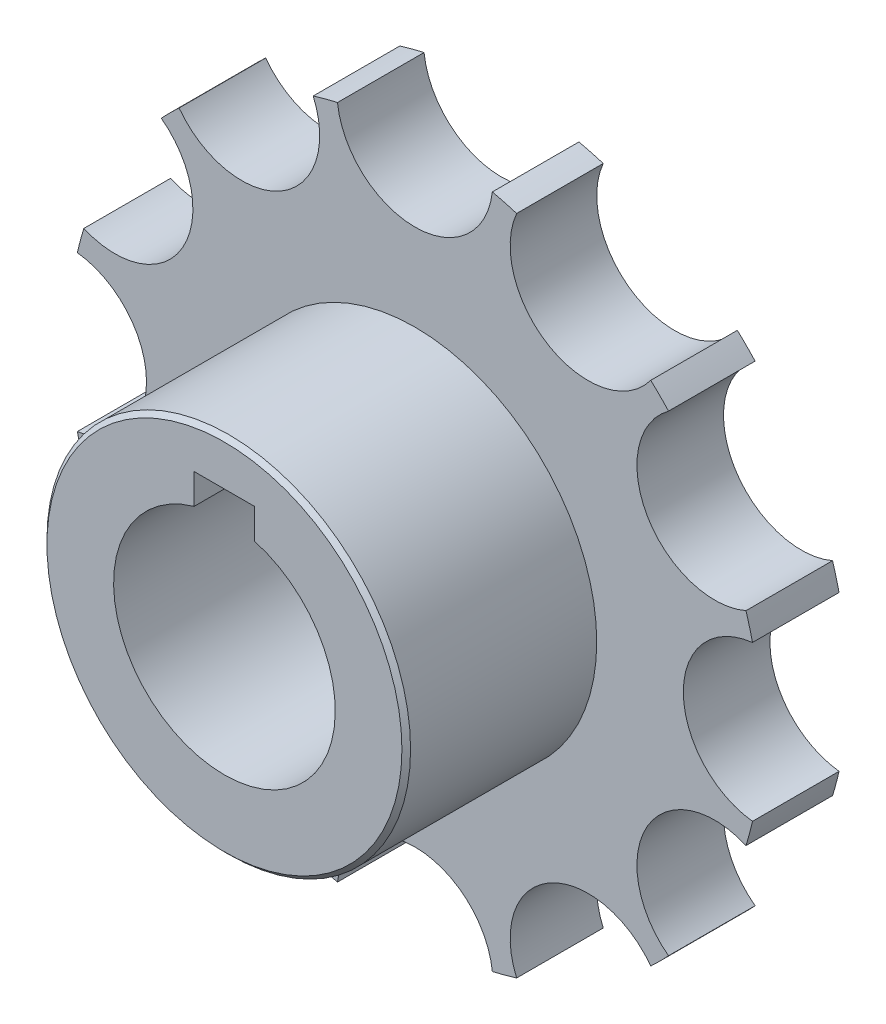
from build123d import *

# Parameters (mm, degrees)
P_IDAT_VYSUNUT_M2_DEPTH  = 10
SKICA2_R                 = 21
P_IDAT_VYSUNUT_M3_DEPTH  = 22
SKICA3_R                 = 12.8
SKICA3_W                 = 7
SKICA3_H                 = 3.487810918
ODEBRAT_VYSUNUT_M1_DEPTH = 61
ZKOSEN_3_SIZE            = 0.5


with BuildPart() as part:
    # Skica1 → Přidat vysunutím2 (new body)
    with BuildSketch(Plane.XY):
        with BuildLine():
            ThreePointArc((38.9875, -8.942865522), (31, 0), (38.9875, 8.942865522))
            ThreePointArc((38.9875, 8.942865522), (38.637033052, 10.352761804), (38.235598191, 11.749001275))
            ThreePointArc((38.235598191, 11.749001275), (26.846787517, 15.5), (29.292732669, 27.238498725))
            ThreePointArc((29.292732669, 27.238498725), (28.284271247, 28.284271247), (27.238498725, 29.292732669))
            ThreePointArc((27.238498725, 29.292732669), (15.5, 26.846787517), (11.749001275, 38.235598191))
            ThreePointArc((11.749001275, 38.235598191), (10.352761804, 38.637033052), (8.942865522, 38.9875))
            ThreePointArc((8.942865522, 38.9875), (0, 31), (-8.942865522, 38.9875))
            ThreePointArc((-8.942865522, 38.9875), (-10.352761804, 38.637033052), (-11.749001275, 38.235598191))
            ThreePointArc((-11.749001275, 38.235598191), (-15.5, 26.846787517), (-27.238498725, 29.292732669))
            ThreePointArc((-27.238498725, 29.292732669), (-28.284271247, 28.284271247), (-29.292732669, 27.238498725))
            ThreePointArc((-29.292732669, 27.238498725), (-26.846787517, 15.5), (-38.235598191, 11.749001275))
            ThreePointArc((-38.235598191, 11.749001275), (-38.637033052, 10.352761804), (-38.9875, 8.942865522))
            ThreePointArc((-38.9875, 8.942865522), (-31, 0), (-38.9875, -8.942865522))
            ThreePointArc((-38.9875, -8.942865522), (-38.637033052, -10.352761804), (-38.235598191, -11.749001275))
            ThreePointArc((-38.235598191, -11.749001275), (-26.846787517, -15.5), (-29.292732669, -27.238498725))
            ThreePointArc((-29.292732669, -27.238498725), (-28.284271247, -28.284271247), (-27.238498725, -29.292732669))
            ThreePointArc((-27.238498725, -29.292732669), (-15.5, -26.846787517), (-11.749001275, -38.235598191))
            ThreePointArc((-11.749001275, -38.235598191), (-10.352761804, -38.637033052), (-8.942865522, -38.9875))
            ThreePointArc((-8.942865522, -38.9875), (0, -31), (8.942865522, -38.9875))
            ThreePointArc((8.942865522, -38.9875), (10.352761804, -38.637033052), (11.749001275, -38.235598191))
            ThreePointArc((11.749001275, -38.235598191), (15.5, -26.846787517), (27.238498725, -29.292732669))
            ThreePointArc((27.238498725, -29.292732669), (28.284271247, -28.284271247), (29.292732669, -27.238498725))
            ThreePointArc((29.292732669, -27.238498725), (26.846787517, -15.5), (38.235598191, -11.749001275))
            ThreePointArc((38.235598191, -11.749001275), (38.637033052, -10.352761804), (38.9875, -8.942865522))
        make_face()
        with BuildLine():
            Line((-3.5, 12.312189082), (-3.5, 15.8))
            Line((-3.5, 15.8), (3.5, 15.8))
            Line((3.5, 15.8), (3.5, 12.312189082))
            ThreePointArc((3.5, 12.312189082), (0, -12.8), (-3.5, 12.312189082))
        make_face(mode=Mode.SUBTRACT)
    extrude(amount=P_IDAT_VYSUNUT_M2_DEPTH)

    # Skica2 → Přidat vysunutím3 (add)
    with BuildSketch(Plane.XY.offset(10)):
        Circle(SKICA2_R)
    extrude(amount=P_IDAT_VYSUNUT_M3_DEPTH)

    # Skica3 → Odebrat vysunutím1 (cut)
    with BuildSketch(Plane(origin=(0, 0, 0), x_dir=(-1, 0, 0), z_dir=(0, 0, -1))):
        Circle(SKICA3_R)
        with Locations((0, 14.056094541)):
            Rectangle(SKICA3_W, SKICA3_H)
    extrude(amount=-ODEBRAT_VYSUNUT_M1_DEPTH, mode=Mode.SUBTRACT)

    # Zkosení3
    zkosen_3_edges = [part.edges().sort_by_distance(p)[0] for p in [
        (-21, 0, 32),
    ]]
    chamfer(zkosen_3_edges, length=ZKOSEN_3_SIZE)


solid = part.part
